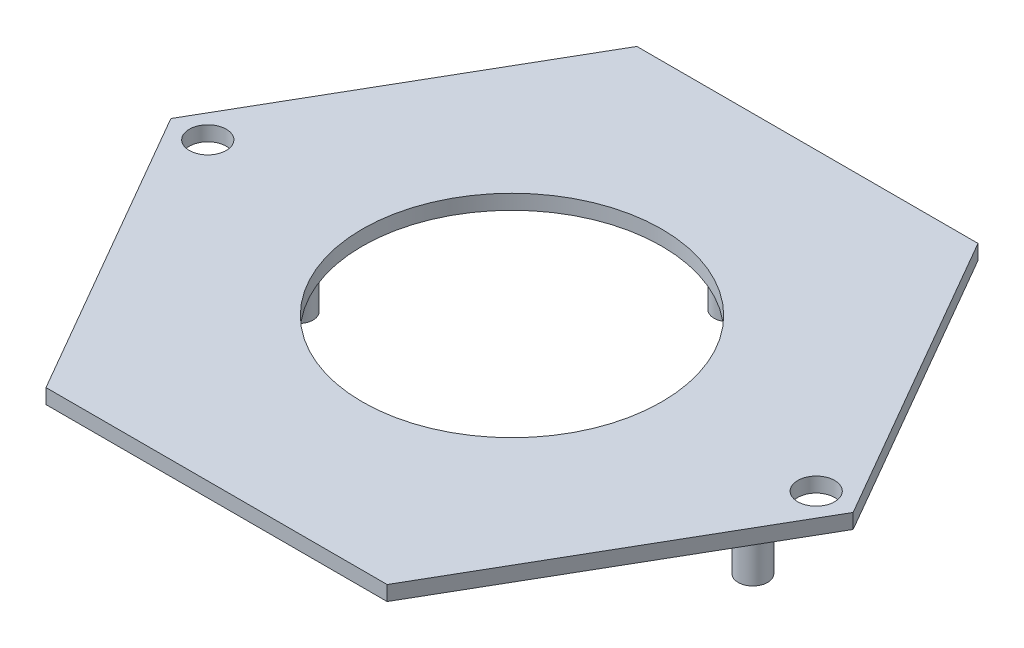
from build123d import *

# Parameters (mm, degrees)
BOSS_EXTRUDE1_DEPTH = 1
SKETCH3_R           = 1
BOSS_EXTRUDE2_DEPTH = 6
SKETCH4_R           = 10.135267165
CUT_EXTRUDE1_DEPTH  = 6
SKETCH5_R           = 1.25
CUT_EXTRUDE2_DEPTH  = 15


with BuildPart() as part:
    # Sketch1 → Boss-Extrude1 (new body)
    with BuildSketch(Plane(origin=(0, 0, 0), x_dir=(1, 0, 0), z_dir=(0, 1, 0))):
        Polygon((23.094010768, 0), (11.547005384, 20), (-11.547005384, 20), (-23.094010768, 0), (-11.547005384, -20), (11.547005384, -20), align=None)
    extrude(amount=BOSS_EXTRUDE1_DEPTH)

    # Sketch3 → Boss-Extrude2 (add)
    with BuildSketch(Plane.XZ):
        with Locations((16.308163565, 0)):
            Circle(SKETCH3_R)
        with Locations((-14.462214845, 0)):
            Circle(SKETCH3_R)
        with Locations((0, -14.675000966)):
            Circle(SKETCH3_R)
    extrude(amount=BOSS_EXTRUDE2_DEPTH)

    # Sketch4 → Cut-Extrude1 (cut)
    with BuildSketch(Plane(origin=(0, 1, 0), x_dir=(1, 0, 0), z_dir=(0, 1, 0))):
        Circle(SKETCH4_R)
    extrude(amount=-CUT_EXTRUDE1_DEPTH, mode=Mode.SUBTRACT)

    # Sketch5 → Cut-Extrude2 (cut)
    with BuildSketch(Plane(origin=(19.371137685, 1, -19.368583248), x_dir=(-1, 0, 0), z_dir=(0, 1, 0))):
        with Locations((-1.222873082, 19.368583248)):
            Circle(SKETCH5_R)
        with Locations((39.965148453, 19.368583248)):
            Circle(SKETCH5_R)
    extrude(amount=-CUT_EXTRUDE2_DEPTH, mode=Mode.SUBTRACT)


solid = part.part
